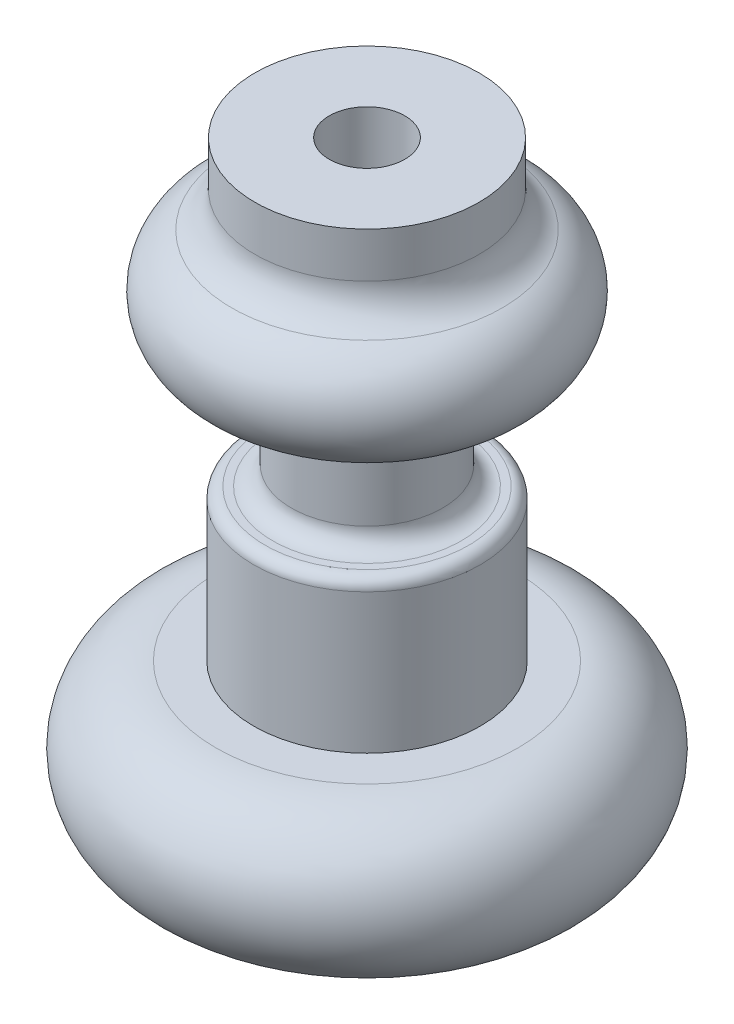
from build123d import *

# Parameters (mm, degrees)
CUT_EXTRUDE1_DEPTH = 10


with BuildPart() as part:
    # Sketch3 → Revolve1 (revolve)
    with BuildSketch(Plane.XY, mode=Mode.PRIVATE) as revolve1_sk:
        with BuildLine():
            Line((0, 0), (0, 120))
            Line((0, 120), (10, 120))
            Line((10, 120), (10, 160))
            Line((10, 160), (29.701425001, 160))
            Line((29.701425001, 160), (29.701425001, 148.044524535))
            ThreePointArc((29.701425001, 148.044524535), (31.371626073, 142.511491929), (35.824314965, 138.826714721))
            ThreePointArc((35.824314965, 138.826714721), (44.711889781, 122.031037674), (30.003459964, 110.000000898))
            ThreePointArc((30.003459964, 110.000000898), (22.930154518, 107.072292046), (19.999998504, 100))
            Line((19.999998504, 100), (19.999998504, 85))
            ThreePointArc((19.999998504, 85), (21.464464598, 81.464466094), (24.999998504, 80))
            Line((24.999998504, 80), (27.00864991, 80))
            ThreePointArc((27.00864991, 80), (29.129970254, 79.121320344), (30.00864991, 77))
            Line((30.00864991, 77), (30.00864991, 40))
            Line((30.00864991, 40), (40, 40))
            ThreePointArc((40, 40), (60, 20), (40, 0))
            Line((40, 0), (0, 0))
        make_face()
    revolve(revolve1_sk.sketch.rotate(Axis((0, 0, 0), (0, 1, 0)), 90), axis=Axis((0, 0, 0), (0, 1, 0)))  # turned: the seam where the file's is

    # Sketch4 → Cut-Extrude1 (cut)
    with BuildSketch(Plane.XZ):
        with BuildLine():
            add(Edge.make_bspline(
                [(7.448828062, -22.678309161), (6.606271612, -23.253020453), (4.920388244, -24.402968576), (2.230254184, -25.851806493), (-0.558158764, -27.012752018), (-2.922702292, -27.744574398), (-4.794090825, -28.151333685), (-6.129562503, -28.357195138), (-7.403842341, -28.51346476), (-8.234025744, -28.524431044), (-8.639607824, -28.529788568)],
                knots=[0, 0, 0, 0, 1.40794664, 2.817180764, 4.210946268, 5.574041327, 6.229144126, 6.854118424, 7.440185107, 8, 8, 8, 8], degree=3))
            add(Edge.make_bspline(
                [(-8.639607824, -28.529788568), (-9.635944293, -28.505265175), (-11.586322463, -28.457259413), (-14.42413454, -27.95243813), (-17.11445001, -27.207988474), (-19.612539432, -26.10745535), (-21.897376027, -24.737689761), (-23.925313076, -23.086848158), (-25.695687433, -21.196229651), (-26.933096475, -19.416410067), (-27.758429021, -17.884899363), (-28.314704699, -16.701137921), (-28.766060766, -15.470346886), (-29.138078794, -14.209637425), (-29.444694629, -12.914210046), (-29.653874746, -11.586506664), (-29.785017422, -10.222054229), (-29.796720622, -9.300822204), (-29.802667179, -8.832731549)],
                knots=[0, 0, 0, 0, 1.473263675, 2.883986888, 4.253760231, 5.596479224, 6.911209549, 8.185729562, 9.454237654, 10.733606613, 11.380952968, 12.028210754, 12.667865357, 13.319243596, 13.973081642, 14.636782931, 15.30733067, 16, 16, 16, 16], degree=3))
            add(Edge.make_bspline(
                [(-29.802667179, -8.832731549), (-29.777608729, -7.991854456), (-29.726136679, -6.264626024), (-29.319184065, -3.61843455), (-28.71047976, -0.848553828), (-27.840566189, 2.006268275), (-26.781308548, 4.886205201), (-25.507282349, 7.700334095), (-24.089294748, 10.435130406), (-22.994798307, 12.166427592), (-22.447595633, 13.032004137)],
                knots=[0, 0, 0, 0, 0.863665488, 1.774037609, 2.745499411, 3.776013129, 4.837853799, 5.896272053, 6.948223572, 8, 8, 8, 8], degree=3))
            add(Edge.make_bspline(
                [(-22.447595633, 13.032004137), (-22.067845629, 13.565796529), (-21.267555247, 14.690717959), (-19.942742802, 16.354193489), (-18.507026462, 17.985537604), (-16.940919933, 19.453510459), (-15.287789462, 20.782230539), (-14.128087687, 21.600289526), (-13.53881221, 22.015967167)],
                knots=[0, 0, 0, 0, 0.92579409, 1.951031201, 3.004601133, 3.994364434, 4.980882949, 6, 6, 6, 6], degree=3))
            add(Edge.make_bspline(
                [(-13.53881221, 22.015967167), (-12.946020075, 22.403397544), (-11.747212959, 23.186900335), (-9.840976321, 24.241047645), (-7.854745751, 25.263940322), (-5.766844585, 26.19232142), (-3.628297641, 27.052837803), (-1.464393958, 27.81928745), (0.707692642, 28.468280915), (2.871637232, 29.022569045), (5.012417735, 29.460122448), (7.107607434, 29.7740231), (9.140714292, 29.972106278), (10.476473378, 29.997561289), (11.132628802, 30.010065372)],
                knots=[0, 0, 0, 0, 0.970245976, 1.962134298, 2.983577461, 4.031495146, 5.092325157, 6.142366917, 7.176419295, 8.198231294, 9.202969318, 10.169561125, 11.100846545, 12, 12, 12, 12], degree=3))
            add(Edge.make_bspline(
                [(11.132628802, 30.010065372), (11.541837002, 30.000573427), (12.294528318, 29.983114087), (13.330245301, 29.916751518), (14.159405357, 29.736720918), (14.821780355, 29.525886887), (15.312354967, 29.196560726), (15.671755149, 28.781668986), (15.878296234, 28.256234485), (15.896835132, 27.877588157), (15.906533843, 27.679497557)],
                knots=[0, 0, 0, 0, 1.641541567, 3.019426499, 4.149023524, 5.038746405, 5.786373427, 6.487365927, 7.208658398, 8, 8, 8, 8], degree=3))
            add(Edge.make_bspline(
                [(15.906533843, 27.679497557), (15.890475066, 27.485523395), (15.856670145, 27.077193336), (15.612082984, 26.465578628), (15.21421776, 25.847766902), (14.864628081, 25.464936479), (14.678600263, 25.2612202)],
                knots=[0, 0, 0, 0, 0.837421179, 1.762833947, 2.80953259, 4, 4, 4, 4], degree=3))
            add(Edge.make_bspline(
                [(14.678600263, 25.2612202), (14.40042273, 25.047366074), (13.75414242, 24.550526125), (12.484892931, 23.9544298), (10.848636508, 23.34558419), (9.615428148, 22.98845469), (8.939890266, 22.792823106)],
                knots=[0, 0, 0, 0, 0.667924494, 1.551766045, 2.658884553, 4, 4, 4, 4], degree=3))
            add(Edge.make_bspline(
                [(8.939890266, 22.792823106), (8.026273626, 22.548616738), (6.263921867, 22.077546593), (3.772060242, 21.227937251), (1.522927378, 20.291005118), (-0.481933271, 19.249128373), (-2.28043038, 18.099725543), (-3.875227843, 16.809371101), (-5.323170668, 15.412147544), (-6.140902545, 14.36608084), (-6.547108765, 13.846449879)],
                knots=[0, 0, 0, 0, 1.24257322, 2.396903694, 3.457140911, 4.441654627, 5.362799603, 6.256906447, 7.134122735, 8, 8, 8, 8], degree=3))
            add(Edge.make_bspline(
                [(-6.547108765, 13.846449879), (-7.019539183, 13.173876298), (-7.975932874, 11.812310439), (-9.189670998, 9.583699965), (-10.301120602, 7.216633275), (-11.23460707, 4.716793114), (-11.989426962, 2.18311772), (-12.551733854, -0.310021596), (-12.889543336, -2.729694063), (-12.938503164, -4.320976225), (-12.962435224, -5.098811071)],
                knots=[0, 0, 0, 0, 0.971041303, 1.965787423, 2.995286767, 4.061038321, 5.117205811, 6.118792112, 7.080446521, 8, 8, 8, 8], degree=3))
            add(Edge.make_bspline(
                [(-12.962435224, -5.098811071), (-12.951916637, -5.596119147), (-12.931192397, -6.575940093), (-12.79425279, -8.017062747), (-12.557430292, -9.39977656), (-12.218477985, -10.724363651), (-11.775183915, -11.990928241), (-11.254478827, -13.211290243), (-10.62277697, -14.364716947), (-9.912758798, -15.451610166), (-9.135071695, -16.447108992), (-8.293414402, -17.320063719), (-7.395348059, -18.052589811), (-6.456167553, -18.659589985), (-5.468291511, -19.124879153), (-4.440434816, -19.472146751), (-3.360061667, -19.675605144), (-2.621900465, -19.697609043), (-2.249341234, -19.708714687)],
                knots=[0, 0, 0, 0, 1.188438066, 2.341519408, 3.455713451, 4.537837945, 5.604757056, 6.659797926, 7.704924517, 8.743069174, 9.759441477, 10.719406149, 11.634473885, 12.523252494, 13.384940295, 14.237153283, 15.110269118, 16, 16, 16, 16], degree=3))
            add(Edge.make_bspline(
                [(-2.249341234, -19.708714687), (-1.798553974, -19.679602865), (-0.877715542, -19.620135159), (0.471211711, -19.121432883), (1.783457611, -18.327898689), (2.565431091, -17.614535911), (2.975641448, -17.240317592)],
                knots=[0, 0, 0, 0, 0.910887482, 1.860700769, 2.877758996, 4, 4, 4, 4], degree=3))
            add(Edge.make_bspline(
                [(2.975641448, -17.240317592), (2.91081397, -17.122091196), (2.724938843, -16.783109224), (2.489766388, -16.475704275), (2.336614789, -16.275512636)],
                knots=[0, 0, 0, 0, 0.697537958, 2, 2, 2, 2], degree=3))
            add(Edge.make_bspline(
                [(2.336614789, -16.275512636), (2.073712067, -15.859126662), (1.571257332, -15.063337627), (0.791475228, -13.9814757), (0.031019874, -13.063263047), (-0.719740557, -12.28644631), (-1.530220578, -11.629955587), (-2.412091248, -11.019754616), (-3.415046676, -10.473911412), (-4.134658349, -10.159636198), (-4.504729443, -9.998015457)],
                knots=[0, 0, 0, 0, 1.2469786, 2.383202027, 3.374592258, 4.264706539, 5.113906436, 6.011718267, 6.977496304, 8, 8, 8, 8], degree=3))
            add(Edge.make_bspline(
                [(-4.504729443, -9.998015457), (-4.755753471, -9.873648135), (-5.219416567, -9.643930933), (-5.855573463, -9.312553728), (-6.351187676, -8.98818967), (-6.842247813, -8.620027433), (-7.260845479, -8.061058867), (-7.319988096, -7.544941155), (-7.349024572, -7.291549607)],
                knots=[0, 0, 0, 0, 1.215029776, 2.244265109, 3.108370656, 3.778781372, 4.909477402, 6, 6, 6, 6], degree=3))
            add(Edge.make_bspline(
                [(-7.349024572, -7.291549607), (-7.33125161, -7.102349605), (-7.29451897, -6.711316561), (-6.912036926, -6.192837631), (-6.373554251, -5.71128293), (-5.629303628, -5.290661763), (-4.744997304, -4.917768472), (-3.730530729, -4.663615787), (-2.622621318, -4.494191439), (-1.84909033, -4.479791619), (-1.447425427, -4.472314346)],
                knots=[0, 0, 0, 0, 0.63500194, 1.312403485, 2.116627864, 3.090688551, 4.198216403, 5.372626698, 6.635706054, 8, 8, 8, 8], degree=3))
            add(Edge.make_bspline(
                [(-1.447425427, -4.472314346), (-0.936687516, -4.484211163), (0.07860629, -4.507860795), (1.572026868, -4.775901967), (3.030693692, -5.169526935), (4.453102982, -5.766193667), (5.887174236, -6.529796083), (7.353261939, -7.492466359), (8.873276015, -8.647940894), (9.86457291, -9.527446004), (10.380832733, -9.985485522)],
                knots=[0, 0, 0, 0, 0.915031058, 1.818986502, 2.713204933, 3.62022816, 4.578662792, 5.623812799, 6.762499924, 8, 8, 8, 8], degree=3))
            add(Edge.make_bspline(
                [(10.380832733, -9.985485522), (10.494059026, -9.630606678), (10.691201464, -9.012714153), (10.93764376, -8.22209401), (11.107325859, -7.715801995), (11.174835596, -7.467099597), (11.195278474, -7.391789082)],
                knots=[0, 0, 0, 0, 1.644142761, 2.862677048, 3.655602933, 4, 4, 4, 4], degree=3))
            add(Edge.make_bspline(
                [(11.195278474, -7.391789082), (11.308491671, -7.001142409), (11.54550942, -6.18330316), (11.736883177, -4.852894229), (11.886401989, -3.385669508), (11.893329318, -2.355249166), (11.896954806, -1.815968234)],
                knots=[0, 0, 0, 0, 0.8642447, 1.809341496, 2.853496665, 4, 4, 4, 4], degree=3))
            add(Edge.make_bspline(
                [(11.896954806, -1.815968234), (11.883618567, -0.949963989), (11.858382802, 0.688749833), (11.510606072, 3.032145836), (11.000422368, 5.194159498), (10.373957875, 6.90659541), (9.747498818, 8.258357405), (9.217253171, 9.332155773), (8.553368043, 10.426517617), (8.080843547, 11.170135208), (7.837256031, 11.553471868)],
                knots=[0, 0, 0, 0, 1.461943771, 2.766392288, 3.993666152, 5.210404406, 5.838857436, 6.511114878, 7.232476134, 8, 8, 8, 8], degree=3))
            add(Edge.make_bspline(
                [(7.837256031, 11.553471868), (7.60440742, 11.900112613), (7.174446375, 12.540193808), (6.690068721, 13.471634767), (6.360909702, 14.276495039), (6.30750691, 14.784005207), (6.283544154, 15.011733787)],
                knots=[0, 0, 0, 0, 1.305143121, 2.409980883, 3.286530954, 4, 4, 4, 4], degree=3))
            add(Edge.make_bspline(
                [(6.283544154, 15.011733787), (6.293441895, 15.255785488), (6.313452618, 15.749196145), (6.551082651, 16.472998041), (6.888198533, 17.200777548), (7.387819611, 17.908900165), (8.009998004, 18.617826878), (8.769837086, 19.317283923), (9.658795074, 20.021901552), (10.322559114, 20.451190197), (10.669021226, 20.675264177)],
                knots=[0, 0, 0, 0, 0.782092386, 1.581192492, 2.42852655, 3.356384436, 4.356061057, 5.458674575, 6.673515105, 8, 8, 8, 8], degree=3))
            add(Edge.make_bspline(
                [(10.669021226, 20.675264177), (11.214219185, 20.996078319), (12.238639666, 21.598884277), (13.773043538, 22.272852777), (15.195181585, 22.694730403), (16.113007755, 22.761402097), (16.545560502, 22.792823106)],
                knots=[0, 0, 0, 0, 1.200679909, 2.256063265, 3.1781182, 4, 4, 4, 4], degree=3))
            add(Edge.make_bspline(
                [(16.545560502, 22.792823106), (16.859885746, 22.786134133), (17.477071396, 22.773000165), (18.37097349, 22.582313614), (19.221999305, 22.318468946), (20.002606228, 21.902927059), (20.738201469, 21.399099098), (21.423477398, 20.780713334), (22.030036728, 20.030978379), (22.598028872, 19.191246315), (23.094624094, 18.247537417), (23.535362964, 17.212858381), (23.908540872, 16.089844269), (24.205496968, 14.877849062), (24.446805607, 13.585872553), (24.602211149, 12.203877911), (24.705158264, 10.736402077), (24.719986047, 9.728466462), (24.727607724, 9.210374118)],
                knots=[0, 0, 0, 0, 0.850262877, 1.669512886, 2.467846467, 3.25770707, 4.055317922, 4.880801615, 5.749037393, 6.662727757, 7.624991437, 8.634317334, 9.708297899, 10.828537369, 12.014247367, 13.268196014, 14.59581633, 16, 16, 16, 16], degree=3))
            add(Edge.make_bspline(
                [(24.727607724, 9.210374118), (24.720133386, 8.566725227), (24.705156418, 7.276991116), (24.515382303, 5.345364818), (24.242051081, 3.417642083), (23.871647706, 1.494223134), (23.36320045, -0.415351801), (22.746989756, -2.316065632), (22.036370159, -4.218398103), (21.476841278, -5.460940871), (21.194166198, -6.088675895)],
                knots=[0, 0, 0, 0, 0.975602137, 1.954897107, 2.940071819, 3.927462718, 4.92284341, 5.934232436, 6.956370206, 8, 8, 8, 8], degree=3))
            add(Edge.make_bspline(
                [(21.194166198, -6.088675895), (20.873644491, -6.705523605), (20.18017542, -8.040112802), (18.942320441, -10.127919887), (17.448251159, -12.455481404), (16.341362838, -14.069161511), (15.756174629, -14.922279711)],
                knots=[0, 0, 0, 0, 0.803404898, 1.738217521, 2.804243921, 4, 4, 4, 4], degree=3))
            add(Edge.make_bspline(
                [(15.756174629, -14.922279711), (16.178589036, -15.331611697), (16.952025048, -16.081093942), (18.172085223, -17.034095995), (19.466677219, -17.747598292), (20.649085376, -18.26993152), (21.781491852, -18.657527207), (22.853416398, -18.979822829), (24.122491243, -19.342108834), (25.040310658, -19.581249024), (25.529523532, -19.708714687)],
                knots=[0, 0, 0, 0, 1.275925323, 2.336204869, 3.346676419, 4.474726713, 5.136740845, 5.942229985, 6.90317467, 8, 8, 8, 8], degree=3))
            add(Edge.make_bspline(
                [(25.529523532, -19.708714687), (25.460469313, -20.178652107), (25.311173859, -21.194658394), (24.853484437, -22.730599844), (24.258590546, -24.28845945), (23.580264856, -25.712769943), (22.880957762, -26.915693463), (22.267380773, -27.487550703), (21.996082005, -27.740402695)],
                knots=[0, 0, 0, 0, 0.956926446, 2.068878205, 3.223408019, 4.316048003, 5.255424975, 6, 6, 6, 6], degree=3))
            add(Edge.make_bspline(
                [(21.996082005, -27.740402695), (21.817067575, -27.866318747), (21.451244867, -28.123632925), (20.781566673, -28.351780544), (20.027880907, -28.50645624), (19.486894933, -28.521738147), (19.201906614, -28.529788568)],
                knots=[0, 0, 0, 0, 0.884395632, 1.807295671, 2.844895895, 4, 4, 4, 4], degree=3))
            add(Edge.make_bspline(
                [(19.201906614, -28.529788568), (18.666380137, -28.512211965), (17.610265526, -28.477549053), (16.060994268, -28.224571277), (14.577353076, -27.792325241), (13.139737787, -27.184275416), (11.730644933, -26.36002653), (10.312864523, -25.331346174), (8.856029212, -24.107387426), (7.929817786, -23.166776613), (7.448828062, -22.678309161)],
                knots=[0, 0, 0, 0, 0.949134154, 1.87179251, 2.773902048, 3.682912807, 4.631584786, 5.660987008, 6.785330021, 8, 8, 8, 8], degree=3))
        make_face()
    extrude(amount=-CUT_EXTRUDE1_DEPTH, mode=Mode.SUBTRACT)


solid = part.part
